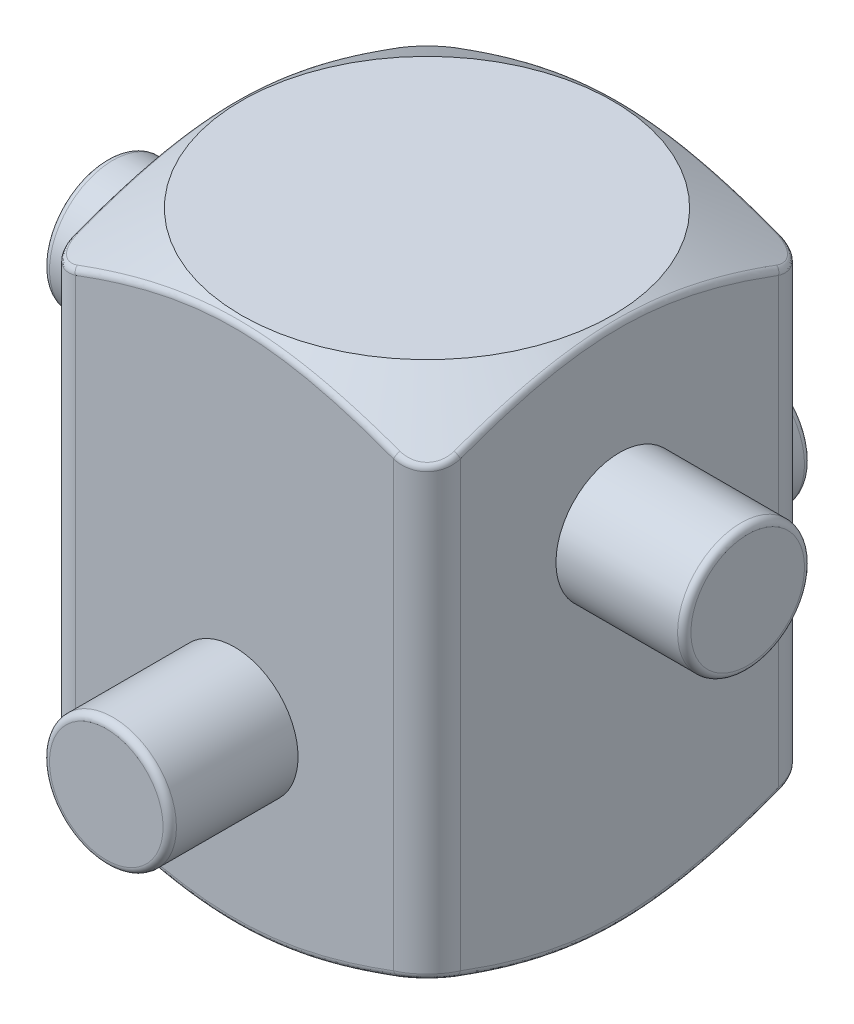
from build123d import *

# Parameters (mm, degrees)
SKETCH1_W           = 14.4
SKETCH1_H           = 14.4
BOSS_EXTRUDE1_DEPTH = 19.7
SKETCH3_R           = 2.375
BOSS_EXTRUDE2_DEPTH = 12
SKETCH4_R           = 2.375
BOSS_EXTRUDE3_DEPTH = 12
FILLET1_R           = 1.25
FILLET2_R           = 0.25


with BuildPart() as part:
    # Sketch1 → Boss-Extrude1 (new body)
    with BuildSketch(Plane(origin=(0, 0, 0), x_dir=(1, 0, 0), z_dir=(0, 1, 0))):
        Rectangle(SKETCH1_W, SKETCH1_H)
    extrude(amount=BOSS_EXTRUDE1_DEPTH)

    # Sketch2 → Cut-Revolve1 (revolve, cut)
    with BuildSketch(Plane.XY):
        Polygon((-6.95, 19.7), (-16.09, 19.7), (-16.09, 0), (-6.95, 0), (-13.55, 3.810511777), (-13.55, 15.889488223), align=None)
    revolve(axis=Axis((0, 20.685, 0), (0, -1, 0)), mode=Mode.SUBTRACT)

    # Sketch3 → Boss-Extrude2 (add, symmetric)
    with BuildSketch(Plane.XY):
        with Locations((0, 6.7)):
            Circle(SKETCH3_R)
    extrude(amount=BOSS_EXTRUDE2_DEPTH, both=True)

    # Sketch4 → Boss-Extrude3 (add, symmetric)
    with BuildSketch(Plane(origin=(0, 0, 0), x_dir=(0, 0, -1), z_dir=(1, 0, 0))):
        with Locations((0, 13)):
            Circle(SKETCH4_R)
    extrude(amount=BOSS_EXTRUDE3_DEPTH, both=True)

    # Fillet1
    fillet1_edges = [part.edges().sort_by_distance(p)[0] for p in [
        (7.2, 9.85, -7.2),
        (7.2, 9.85, 7.2),
        (-7.2, 9.85, 7.2),
        (-7.2, 9.85, -7.2),
    ]]
    fillet(fillet1_edges, radius=FILLET1_R)

    # Fillet2
    fillet2_edges = [part.edges().sort_by_distance(p)[0] for p in [
        (-2.375, 6.7, -12),
        (-2.375, 6.7, 12),
        (-12, 13, 2.375),
        (12, 13, 2.375),
        (0, 19.555662433, -7.2),
        (0, 0.144337567, -7.2),
        (7.2, 0.144337567, 0),
        (0, 0.144337567, 7.2),
        (-7.2, 0.496990622, -3.028002619),
        (-6.833883475, 1.567258122, -6.833883478),
        (-6.833883478, 1.567258122, 6.833883475),
        (6.833883478, 1.567258122, 6.833883475),
        (6.833883475, 1.567258122, -6.833883478),
        (7.2, 19.555662433, 0),
        (0, 19.555662433, 7.2),
        (-7.2, 19.203009378, -3.028002619),
        (-6.833883475, 18.132741878, -6.833883478),
        (-6.833883478, 18.132741878, 6.833883475),
        (6.833883478, 18.132741878, 6.833883475),
        (6.833883475, 18.132741878, -6.833883478),
    ]]
    fillet(fillet2_edges, radius=FILLET2_R)


solid = part.part
